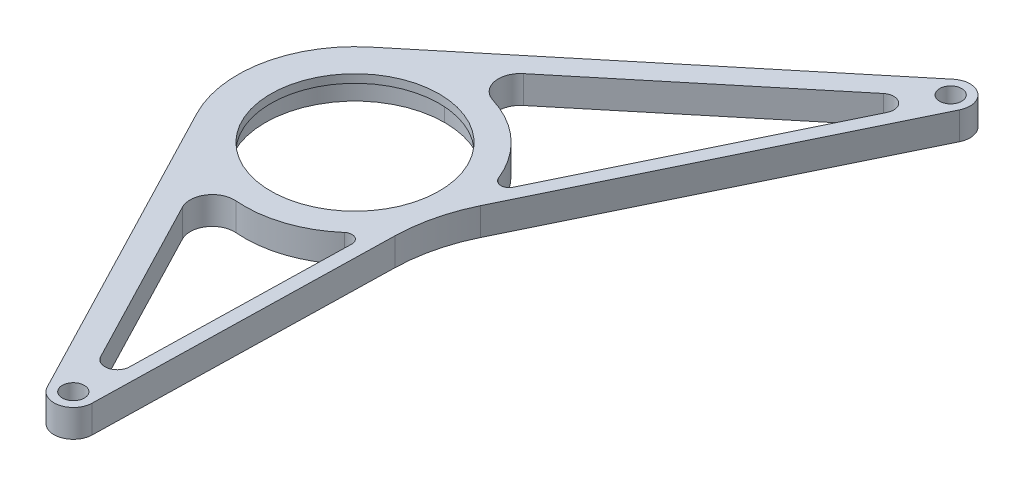
from build123d import *

# Parameters (mm, degrees)
SZKIC2_R                    = 4
SZKIC2_R_2                  = 32.5
DODANIE_WYCI_GNI_CIE1_DEPTH = 10
WYTNIJ_WYCI_GNI_CIE1_DEPTH  = 4
WYTNIJ_WYCI_GNI_CIE2_START  = -10
WYTNIJ_WYCI_GNI_CIE2_DEPTH  = 1741.763240958
DODANIE_WYCI_GNI_CIE2_START = -7
SZKIC4_R                    = 32.5
SZKIC4_R_2                  = 30.5
DODANIE_WYCI_GNI_CIE2_DEPTH = 3
ZAOKR_GLENIE1_R             = 60
ZAOKR_GLENIE2_R             = 8
ZAOKR_GLENIE3_R             = 3


with BuildPart() as part:
    # Szkic2 → Dodanie-wyci_gni_cie1 (new body)
    with BuildSketch(Plane(origin=(0, 0, 0), x_dir=(1, 0, 0), z_dir=(0, 1, 0))):
        with BuildLine():
            Line((1543.993451292, -292.693431604), (1602.649516269, -405.490665796))
            ThreePointArc((1602.649516269, -405.490665796), (1610.447293462, -409.078792342), (1615.858300195, -402.415385751))
            Line((1615.858300195, -402.415385751), (1618.512976907, -281.976412469))
            Line((1618.512976907, -281.976412469), (1680.947289281, -153.356819868))
            ThreePointArc((1680.947289281, -153.356819868), (1678.976293723, -144.796984225), (1670.19309755, -144.902220776))
            Line((1670.19309755, -144.902220776), (1554.640194786, -240.313313752))
            ThreePointArc((1554.640194786, -240.313313752), (1540.051589656, -264.620128285), (1543.993451292, -292.693431604))
        make_face()
        with Locations((1608.86, -402.261131492)):
            Circle(SZKIC2_R, mode=Mode.SUBTRACT)
        with Locations((1581.69995966, -273.085544755)):
            Circle(SZKIC2_R_2, mode=Mode.SUBTRACT)
        with Locations((1674.65, -150.3)):
            Circle(SZKIC2_R, mode=Mode.SUBTRACT)
    extrude(amount=DODANIE_WYCI_GNI_CIE1_DEPTH)

    # Szkic3 → Wytnij-wyci_gni_cie1 (cut)
    with BuildSketch(Plane(origin=(0, 10, 0), x_dir=(1, 0, 0), z_dir=(0, 1, 0))):
        with BuildLine():
            Line((1562.06257658, -307.933402448), (1602.825740378, -386.322093118))
            ThreePointArc((1602.825740378, -386.322093118), (1607.801974735, -388.611894192), (1611.255066167, -384.359570486))
            Line((1611.255066167, -384.359570486), (1613.16331738, -297.784879179))
            ThreePointArc((1613.16331738, -297.784879179), (1589.491721347, -312.31931146), (1562.06257658, -307.933402448))
        make_face()
        with BuildLine():
            Line((1662.025493572, -162.020782011), (1575.342850703, -233.593935954))
            ThreePointArc((1575.342850703, -233.593935954), (1604.608184708, -240.295100641), (1620.968093066, -265.468872331))
            Line((1620.968093066, -265.468872331), (1668.654089364, -167.231970482))
            ThreePointArc((1668.654089364, -167.231970482), (1667.439220484, -161.955917019), (1662.025493572, -162.020782011))
        make_face()
    extrude(amount=-WYTNIJ_WYCI_GNI_CIE1_DEPTH, mode=Mode.SUBTRACT)

    # Szkic3_3 → Wytnij-wyci_gni_cie2 (cut, through all)
    with BuildSketch(Plane(origin=(0, 10, 0), x_dir=(1, 0, 0), z_dir=(0, 1, 0)).offset(WYTNIJ_WYCI_GNI_CIE2_START)):
        with BuildLine():
            Line((1562.06257658, -307.933402448), (1602.825740378, -386.322093118))
            ThreePointArc((1602.825740378, -386.322093118), (1607.801974735, -388.611894192), (1611.255066167, -384.359570486))
            Line((1611.255066167, -384.359570486), (1613.16331738, -297.784879179))
            ThreePointArc((1613.16331738, -297.784879179), (1589.491721347, -312.31931146), (1562.06257658, -307.933402448))
        make_face()
        with BuildLine():
            Line((1662.025493572, -162.020782011), (1575.342850703, -233.593935954))
            ThreePointArc((1575.342850703, -233.593935954), (1604.608184708, -240.295100641), (1620.968093066, -265.468872331))
            Line((1620.968093066, -265.468872331), (1668.654089364, -167.231970482))
            ThreePointArc((1668.654089364, -167.231970482), (1667.439220484, -161.955917019), (1662.025493572, -162.020782011))
        make_face()
    extrude(amount=WYTNIJ_WYCI_GNI_CIE2_DEPTH, mode=Mode.SUBTRACT)

    # Szkic4 → Dodanie-wyci_gni_cie2 (add)
    with BuildSketch(Plane(origin=(0, 0, 0), x_dir=(-1, 0, 0), z_dir=(0, -1, 0)).offset(DODANIE_WYCI_GNI_CIE2_START)):
        with Locations((-1581.69995966, -273.085544755)):
            Circle(SZKIC4_R)
        with Locations((-1581.69995966, -273.085544755)):
            Circle(SZKIC4_R_2, mode=Mode.SUBTRACT)
    extrude(amount=-DODANIE_WYCI_GNI_CIE2_DEPTH)

    # Zaokr_glenie1
    zaokr_glenie1_edges = [part.edges().sort_by_distance(p)[0] for p in [
        (1618.512976907, 5, 281.976412469),
    ]]
    fillet(zaokr_glenie1_edges, radius=ZAOKR_GLENIE1_R)

    # Zaokr_glenie2
    zaokr_glenie2_edges = [part.edges().sort_by_distance(p)[0] for p in [
        (1562.06257658, 5, 307.933402448),
        (1575.342850703, 5, 233.593935954),
    ]]
    fillet(zaokr_glenie2_edges, radius=ZAOKR_GLENIE2_R)

    # Zaokr_glenie3
    zaokr_glenie3_edges = [part.edges().sort_by_distance(p)[0] for p in [
        (1613.16331738, 5, 297.784879179),
        (1620.968093066, 5, 265.468872331),
    ]]
    fillet(zaokr_glenie3_edges, radius=ZAOKR_GLENIE3_R)


solid = part.part
